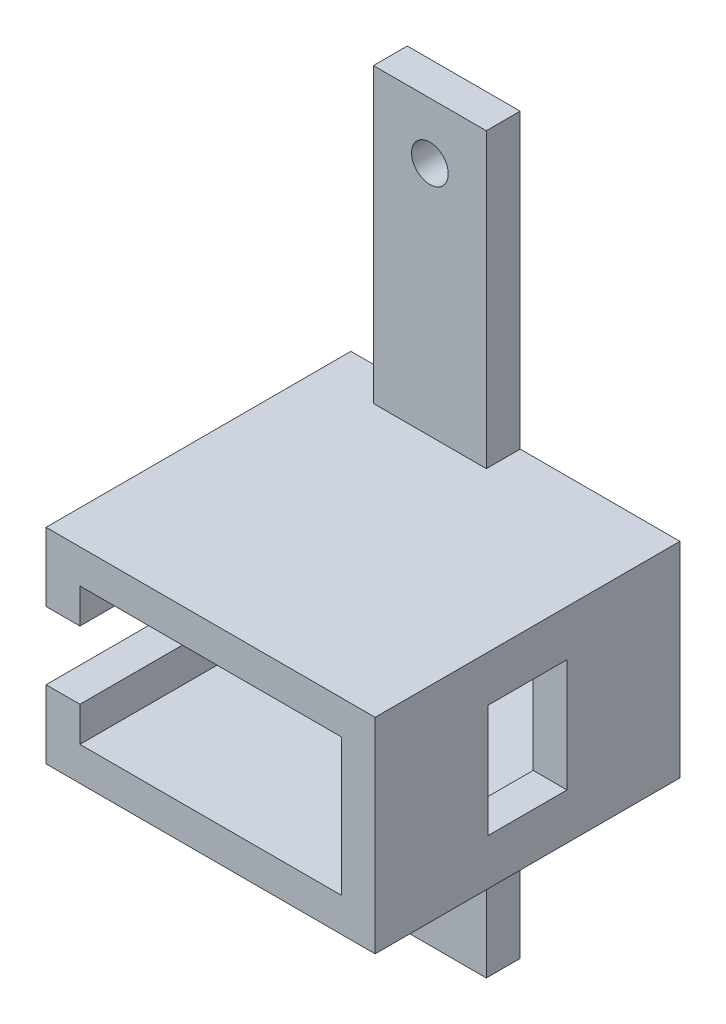
from build123d import *

# Parameters (mm, degrees)
ESQUISSE1_W                = 10
ESQUISSE1_H                = 20.925
BOSS_EXTRU_1_DEPTH         = 3
ESQUISSE1_H_2              = 25.925
BOSS_EXTRU_1_2_DEPTH       = 3
ESQUISSE1_3_W              = 23.15
ESQUISSE1_3_H              = 12.15
BOSS_EXTRU_2_DEPTH         = 27
ESQUISSE3_R                = 1.625
ENL_V_MAT_EXTRU_2_DEPTH    = 74.377261464
R_P_TITION_LIN_AIRE1_COUNT = 2
R_P_TITION_LIN_AIRE1_PITCH = 55
ESQUISSE5_W                = 27
ESQUISSE5_H                = 6
ENL_V_MAT_EXTRU_3_DEPTH    = 10
ENL_V_MAT_EXTRU_4_REACH    = 78.182
ESQUISSE6_W                = 7
ESQUISSE6_H                = 10


with BuildPart() as part:
    # Esquisse1 → Boss.-Extru.1 (new body)
    with BuildSketch(Plane.XY):
        with Locations((5, -54.5375)):
            Rectangle(ESQUISSE1_W, ESQUISSE1_H)
    extrude(amount=BOSS_EXTRU_1_DEPTH)



with BuildPart() as body_2:
    # Esquisse1 → Boss.-Extru.1 2 (new body)
    with BuildSketch(Plane.XY):
        with Locations((5, -12.9625)):
            Rectangle(ESQUISSE1_W, ESQUISSE1_H_2)
    extrude(amount=BOSS_EXTRU_1_2_DEPTH)


with BuildPart() as part_1:
    add(part.part)

    add(body_2.part)  # Boss.-Extru.2 merges body 2
    # Esquisse1_3 → Boss.-Extru.2 (add)
    with BuildSketch(Plane.XY):
        Polygon((0, -44.075), (10, -44.075), (24.15, -44.075), (24.15, -25.925), (10, -25.925), (0, -25.925), (-5, -25.925), (-5, -44.075), align=None)
        with Locations((9.575, -35)):
            Rectangle(ESQUISSE1_3_W, ESQUISSE1_3_H, mode=Mode.SUBTRACT)
    extrude(amount=BOSS_EXTRU_2_DEPTH)

    # Esquisse3 → Enlèv. mat.-Extru.2 (cut, through all)
    with BuildSketch(Plane.XY.offset(3)):
        with Locations((5, -5)):
            Circle(ESQUISSE3_R)
    enl_v_mat_extru_2 = extrude(amount=-ENL_V_MAT_EXTRU_2_DEPTH, mode=Mode.SUBTRACT)

    # Répétition linéaire1: Enlèv. mat.-Extru.2 ×2
    with Locations(*[(0, -i * R_P_TITION_LIN_AIRE1_PITCH, 0) for i in range(1, R_P_TITION_LIN_AIRE1_COUNT)]):
        add(enl_v_mat_extru_2, mode=Mode.SUBTRACT)

    # Esquisse5 → Enlèv. mat.-Extru.3 (cut)
    with BuildSketch(Plane.ZY.offset(5)):
        with Locations((13.5, -35)):
            Rectangle(ESQUISSE5_W, ESQUISSE5_H)
    extrude(amount=-ENL_V_MAT_EXTRU_3_DEPTH, mode=Mode.SUBTRACT)

    # Esquisse6 → Enlèv. mat.-Extru.4 (cut, up to next)
    with BuildSketch(Plane(origin=(24.15, 0, 0), x_dir=(0, 0, -1), z_dir=(1, 0, 0)), mode=Mode.PRIVATE) as enl_v_mat_extru_4_sk1:
        with Locations((-13.5, -35)):
            Rectangle(ESQUISSE6_W, ESQUISSE6_H)
    enl_v_mat_extru_4_tool1 = extrude(enl_v_mat_extru_4_sk1.sketch, amount=-ENL_V_MAT_EXTRU_4_REACH, mode=Mode.PRIVATE) & part_1.part
    add(enl_v_mat_extru_4_tool1.solids().sort_by_distance((24.15, -35, 13.5))[0], mode=Mode.SUBTRACT)


solid = part_1.part
